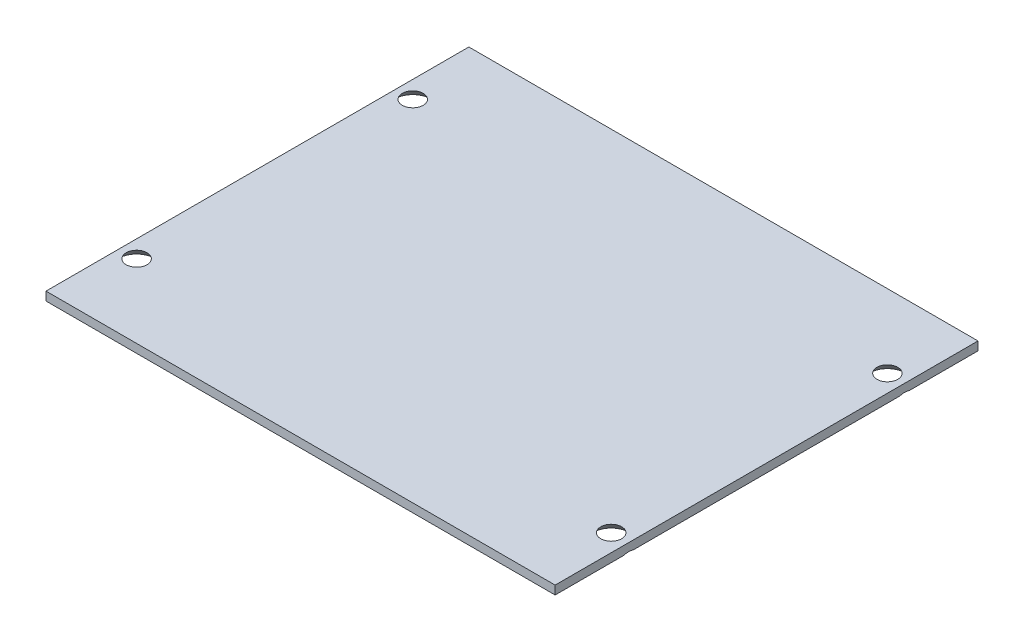
from build123d import *

# Parameters (mm, degrees)
SKETCH1_W                                     = 93.6625
SKETCH1_H                                     = 77.7875
BOSS_EXTRUDE1_DEPTH                           = 1.5875
CSK_FOR_4_FLAT_HEAD_MACHINE_SCREW1_AT_2_COUNT = 2
CSK_FOR_4_FLAT_HEAD_MACHINE_SCREW1_AT_2_PITCH = 50.8
CSK_FOR_4_FLAT_HEAD_MACHINE_SCREW1_AT_3_COUNT = 2
CSK_FOR_4_FLAT_HEAD_MACHINE_SCREW1_AT_3_PITCH = 101.015408014
CSK_FOR_4_FLAT_HEAD_MACHINE_SCREW1_AT_4_COUNT = 2
CSK_FOR_4_FLAT_HEAD_MACHINE_SCREW1_AT_4_PITCH = 87.3125


with BuildPart() as part:
    # Sketch1 → Boss-Extrude1 (new body)
    with BuildSketch(Plane(origin=(0, 0, 0), x_dir=(1, 0, 0), z_dir=(0, 1, 0))):
        Rectangle(SKETCH1_W, SKETCH1_H)
    extrude(amount=BOSS_EXTRUDE1_DEPTH)

    # Sketch3 → CSK for #4 Flat Head Machine Screw1 (revolve, cut)
    with BuildSketch(Plane(origin=(43.65625, 0, -25.4), x_dir=(0, 0, -1), z_dir=(1, 0, 0))):
        Polygon((0, 0), (0, 1.5875), (1.63195, 1.5875), (1.63195, 1.917827142), (3.2990917, 0), align=None)
    csk_for_4_flat_head_machine_screw1 = revolve(axis=Axis((43.65625, -6.35, -25.4), (0, 1, 0)), mode=Mode.SUBTRACT)

    # CSK for #4 Flat Head Machine Screw1 at 2: CSK for #4 Flat Head Machine Screw1 ×2
    with Locations(*[(0, 0, i * CSK_FOR_4_FLAT_HEAD_MACHINE_SCREW1_AT_2_PITCH) for i in range(1, CSK_FOR_4_FLAT_HEAD_MACHINE_SCREW1_AT_2_COUNT)]):
        add(csk_for_4_flat_head_machine_screw1, mode=Mode.SUBTRACT)

    # CSK for #4 Flat Head Machine Screw1 at 3: CSK for #4 Flat Head Machine Screw1 ×2
    with Locations(*[Vector(-0.864348338, 0, 0.502893578) * (i * CSK_FOR_4_FLAT_HEAD_MACHINE_SCREW1_AT_3_PITCH) for i in range(1, CSK_FOR_4_FLAT_HEAD_MACHINE_SCREW1_AT_3_COUNT)]):
        add(csk_for_4_flat_head_machine_screw1, mode=Mode.SUBTRACT)

    # CSK for #4 Flat Head Machine Screw1 at 4: CSK for #4 Flat Head Machine Screw1 ×2
    with Locations(*[(-i * CSK_FOR_4_FLAT_HEAD_MACHINE_SCREW1_AT_4_PITCH, 0, 0) for i in range(1, CSK_FOR_4_FLAT_HEAD_MACHINE_SCREW1_AT_4_COUNT)]):
        add(csk_for_4_flat_head_machine_screw1, mode=Mode.SUBTRACT)


solid = part.part
